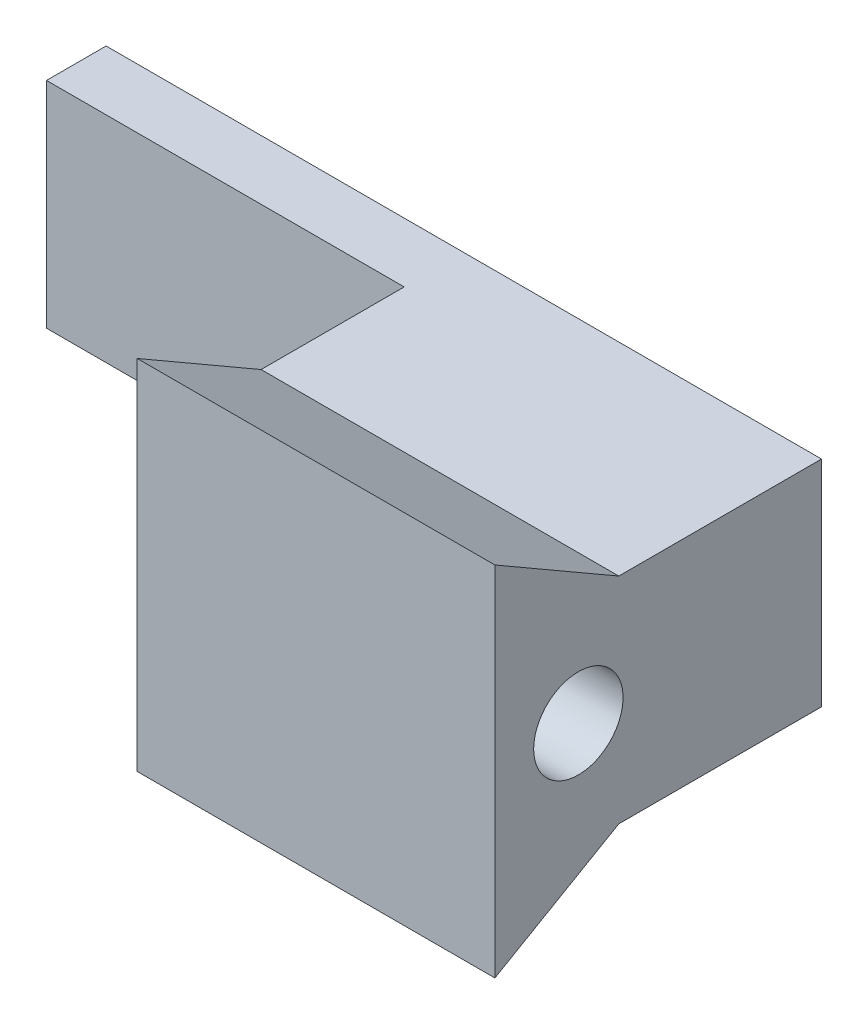
from build123d import *

# Parameters (mm, degrees)
BOSS_EXTRUDE1_DEPTH    = 3
M1X0_25_TAPPED_HOLE1_D = 0.75
SKETCH1_5_W            = 0.5
SKETCH1_5_H            = 1.8
BOSS_EXTRUDE2_DEPTH    = 3


with BuildPart() as part:
    # Sketch1 → Boss-Extrude1 (new body)
    with BuildSketch(Plane(origin=(0, 0, 0), x_dir=(0, 0, -1), z_dir=(1, 0, 0))):
        Polygon((0, 1.5), (0, -1.5), (1.039230485, -0.9), (2.739230485, -0.9), (2.739230485, 0.9), (1.039230485, 0.9), align=None)
    extrude(amount=BOSS_EXTRUDE1_DEPTH)

    # M1x0.25 Tapped Hole1 (through all)
    with Locations(Plane.ZY):
        with Locations((-0.7, 0)):
            Hole(M1X0_25_TAPPED_HOLE1_D / 2)

    # Sketch1_5 → Boss-Extrude2 (add)
    with BuildSketch(Plane(origin=(0, 0, 0), x_dir=(0, 0, -1), z_dir=(1, 0, 0))):
        with Locations((2.489230485, 0)):
            Rectangle(SKETCH1_5_W, SKETCH1_5_H)
    extrude(amount=-BOSS_EXTRUDE2_DEPTH)


solid = part.part
